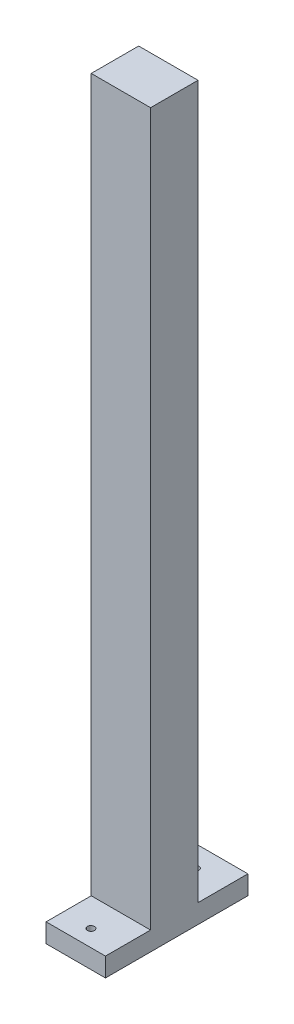
from build123d import *

# Parameters (mm, degrees)
BOSS_EXTRUDE1_DEPTH      = 15
BOSS_EXTRUDE1_DEPTH_BACK = 10
SKETCH3_R                = 1.5
CUT_EXTRUDE2_DEPTH       = 9


with BuildPart() as part:
    # Sketch2 → Boss-Extrude1 (new body, two sides)
    with BuildSketch(Plane(origin=(0, 0, 0), x_dir=(0, 0, -1), z_dir=(1, 0, 0))) as boss_extrude1_sk:
        Polygon((-10, 8), (-10, 308), (10, 308), (10, 8), (31, 8), (31, 0), (-29, 0), (-29, 8), align=None)
    extrude(amount=BOSS_EXTRUDE1_DEPTH)
    extrude(boss_extrude1_sk.sketch, amount=-BOSS_EXTRUDE1_DEPTH_BACK)

    # Sketch3 → Cut-Extrude2 (cut, through all)
    with BuildSketch(Plane(origin=(0, 8, 0), x_dir=(1, 0, 0), z_dir=(0, 1, 0))):
        with Locations((1.863320083, -22)):
            Circle(SKETCH3_R)
    cut_extrude2 = extrude(amount=-CUT_EXTRUDE2_DEPTH, mode=Mode.SUBTRACT)

    # Mirror2: Cut-Extrude2 across plane
    add(cut_extrude2.mirror(Plane.XY), mode=Mode.SUBTRACT)


solid = part.part
